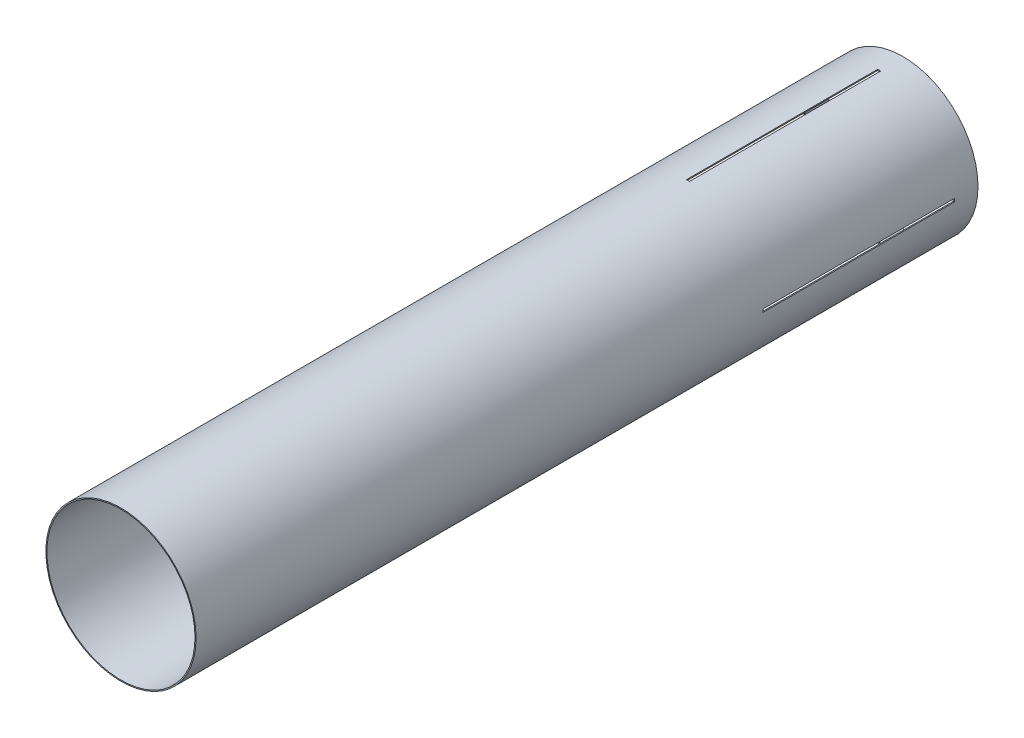
from build123d import *

# Parameters (mm, degrees)
SKETCH1_R           = 80.518
SKETCH1_R_2         = 79.375
BOSS_EXTRUDE1_DEPTH = 838.2
SKETCH3_W           = 3.2004
SKETCH3_H           = 204.978
CUT_EXTRUDE1_DEPTH  = 1.159132
CIRPATTERN1_COUNT   = 4


with BuildPart() as part:
    # Sketch1 → Boss-Extrude1 (new body)
    with BuildSketch(Plane.XY):
        Circle(SKETCH1_R)
        Circle(SKETCH1_R_2, mode=Mode.SUBTRACT)
    extrude(amount=BOSS_EXTRUDE1_DEPTH)

    # Sketch3 → Cut-Extrude1 (cut)
    with BuildSketch(Plane(origin=(0, 80.518, 0), x_dir=(1, 0, 0), z_dir=(0, 1, 0))):
        with Locations((0, -127.889)):
            Rectangle(SKETCH3_W, SKETCH3_H)
    cut_extrude1 = extrude(amount=-CUT_EXTRUDE1_DEPTH, mode=Mode.SUBTRACT)

    # CirPattern1: Cut-Extrude1 ×4 about axis
    cirpattern1_axis = Axis((0, 0, 0), (0, 0, 1))
    for i in range(1, CIRPATTERN1_COUNT):
        add(cut_extrude1.rotate(cirpattern1_axis, i * 360 / CIRPATTERN1_COUNT), mode=Mode.SUBTRACT)


solid = part.part
